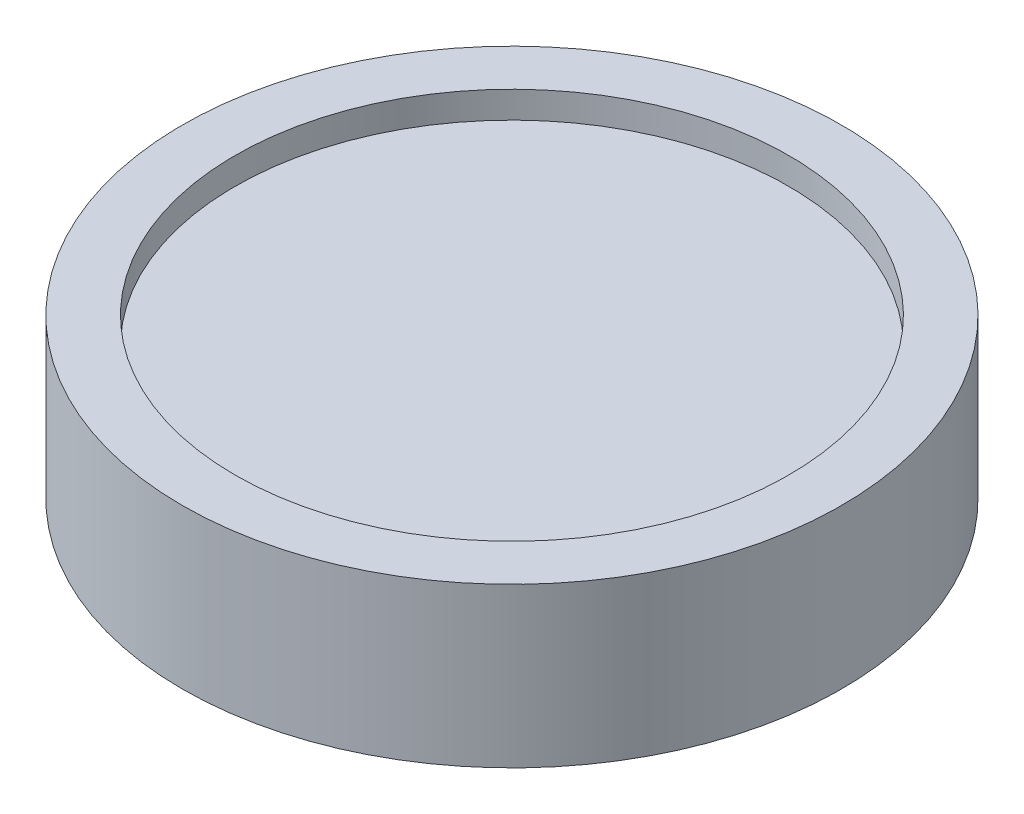
from build123d import *

# Parameters (mm, degrees)
SKETCH1_R                = 10.5
BOSS_EXTRUDE1_DEPTH      = 2
BOSS_EXTRUDE2_START      = -2
SKETCH1_2_R              = 10.5
BOSS_EXTRUDE2_DEPTH      = 2
BOSS_EXTRUDE3_DEPTH      = 3.015
BOSS_EXTRUDE3_DEPTH_BACK = 3.015
SKETCH2_R                = 12.5
SKETCH2_R_2              = 10.5


with BuildPart() as part:
    # Sketch1 → Boss-Extrude1 (new body)
    with BuildSketch(Plane(origin=(0, 0, 0), x_dir=(1, 0, 0), z_dir=(0, 1, 0))):
        Circle(SKETCH1_R)
    extrude(amount=BOSS_EXTRUDE1_DEPTH)

    # Sketch1_2 → Boss-Extrude2 (add)
    with BuildSketch(Plane(origin=(0, 0, 0), x_dir=(1, 0, 0), z_dir=(0, 1, 0)).offset(BOSS_EXTRUDE2_START)):
        Circle(SKETCH1_2_R)
    extrude(amount=BOSS_EXTRUDE2_DEPTH)

    # Sketch2 → Boss-Extrude3 (add, two sides: drawn at the far end of the back side and taken through both)
    with BuildSketch(Plane(origin=(0, 0, 0), x_dir=(1, 0, 0), z_dir=(0, 1, 0)).offset(-BOSS_EXTRUDE3_DEPTH_BACK)):
        Circle(SKETCH2_R)
        Circle(SKETCH2_R_2, mode=Mode.SUBTRACT)
    extrude(amount=BOSS_EXTRUDE3_DEPTH + BOSS_EXTRUDE3_DEPTH_BACK)


solid = part.part
